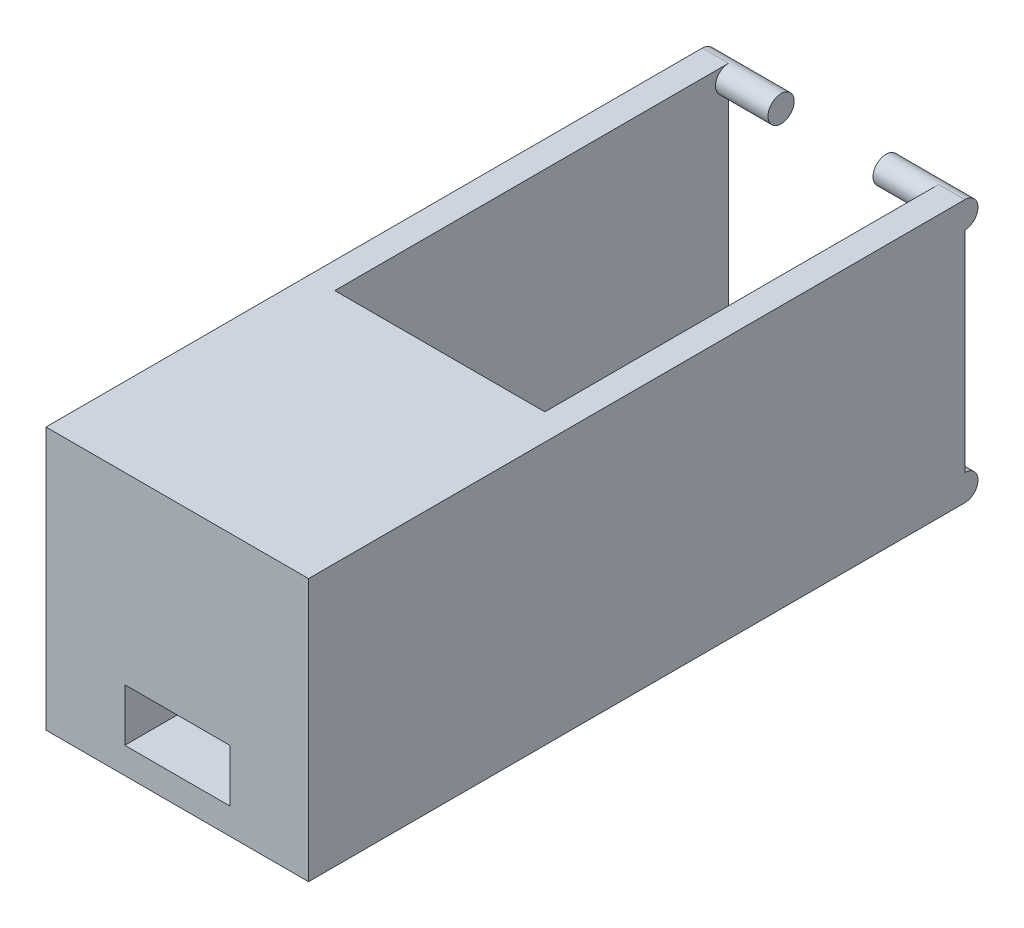
from build123d import *

# Parameters (mm, degrees)
SKETCH_1_W          = 20
SKETCH_1_H          = 50
EXTRUDE_1_DEPTH     = 20
SKETCH_2_W          = 16
SKETCH_2_H          = 30
CUT_EXTRUDE_1_DEPTH = 18
SKETCH_3_W          = 8
SKETCH_3_H          = 38.402735184
CUT_EXTRUDE_2_DEPTH = 18
SKETCH_4_R          = 1
EXTRUDE_2_DEPTH     = 6
SKETCH_5_R          = 1
EXTRUDE_3_DEPTH     = 6
SKETCH_6_W          = 8
SKETCH_6_H          = 4
CUT_EXTRUDE_3_DEPTH = 30


with BuildPart() as part:
    # 草图1 → 凸台-拉伸1 (new body)
    with BuildSketch(Plane(origin=(0, 0, 0), x_dir=(1, 0, 0), z_dir=(0, 1, 0))):
        with Locations((0, 5)):
            Rectangle(SKETCH_1_W, SKETCH_1_H)
    extrude(amount=EXTRUDE_1_DEPTH)

    # 草图2 → 切除-拉伸1 (cut)
    with BuildSketch(Plane(origin=(0, 20, 0), x_dir=(1, 0, 0), z_dir=(0, 1, 0))):
        with Locations((0, 15)):
            Rectangle(SKETCH_2_W, SKETCH_2_H)
    extrude(amount=-CUT_EXTRUDE_1_DEPTH, mode=Mode.SUBTRACT)

    # 草图3 → 切除-拉伸2 (cut)
    with BuildSketch(Plane.XZ):
        with Locations((0, -23.201367592)):
            Rectangle(SKETCH_3_W, SKETCH_3_H)
    extrude(amount=-CUT_EXTRUDE_2_DEPTH, mode=Mode.SUBTRACT)

    # 草图4 → 凸台-拉伸2 (add)
    with BuildSketch(Plane(origin=(-4, 0, 0), x_dir=(0, 0, -1), z_dir=(1, 0, 0))):
        with Locations((30, 1)):
            Circle(SKETCH_4_R)
        with Locations((30, 19)):
            Circle(SKETCH_4_R)
    extrude(amount=-EXTRUDE_2_DEPTH)

    # 草图5 → 凸台-拉伸3 (add)
    with BuildSketch(Plane.ZY.offset(-4)):
        with Locations((-30, 1)):
            Circle(SKETCH_5_R)
        with Locations((-30, 19)):
            Circle(SKETCH_5_R)
    extrude(amount=-EXTRUDE_3_DEPTH)

    # 草图6 → 切除-拉伸3 (cut)
    with BuildSketch(Plane(origin=(0, 0, 0), x_dir=(-1, 0, 0), z_dir=(0, 0, -1))):
        with Locations((0, 4)):
            Rectangle(SKETCH_6_W, SKETCH_6_H)
    extrude(amount=-CUT_EXTRUDE_3_DEPTH, mode=Mode.SUBTRACT)


solid = part.part
